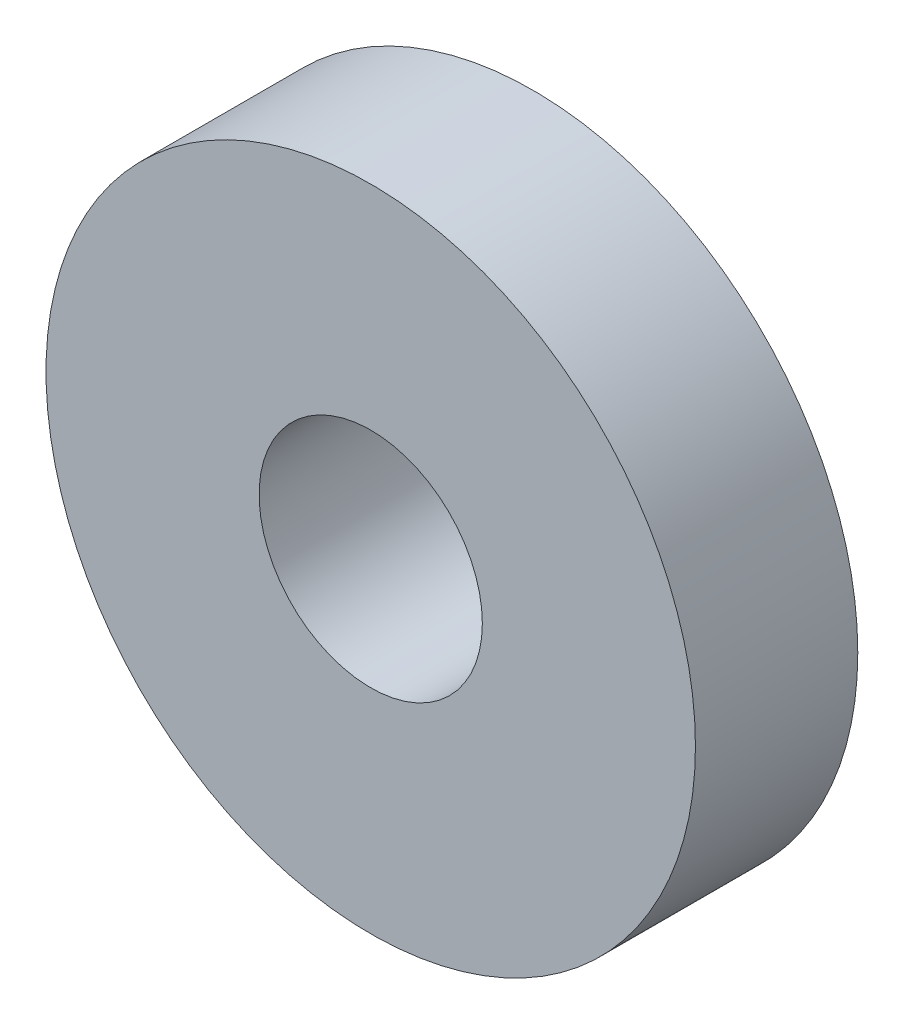
from build123d import *

# Parameters (mm, degrees)
SKETCH1_R           = 3.2
SKETCH1_R_2         = 1.1
BOSS_EXTRUDE1_DEPTH = 1.6


with BuildPart() as part:
    # Sketch1 → Boss-Extrude1 (new body)
    with BuildSketch(Plane.XY):
        Circle(SKETCH1_R)
        Circle(SKETCH1_R_2, mode=Mode.SUBTRACT)
    extrude(amount=BOSS_EXTRUDE1_DEPTH)


solid = part.part
